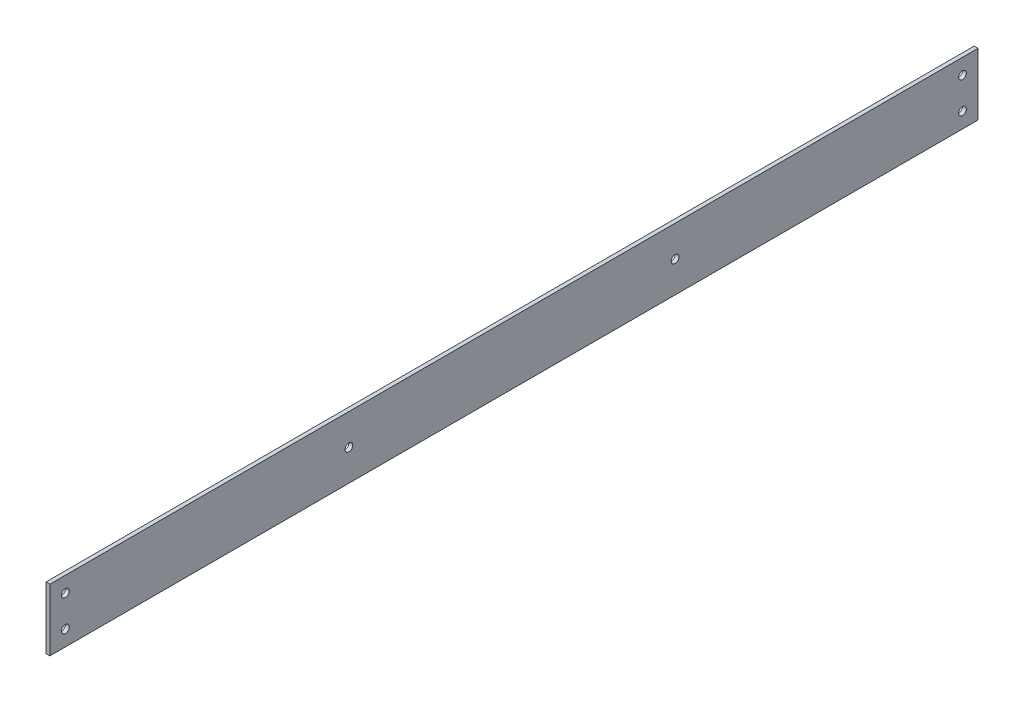
from build123d import *

# Parameters (mm, degrees)
SKETCH1_W           = 3.175
SKETCH1_H           = 50.8
BOSS_EXTRUDE1_DEPTH = 809.625
SKETCH2_R           = 3.175
CUT_EXTRUDE1_DEPTH  = 4.175
SKETCH3_W           = 25.4
SKETCH3_H           = 50.8
CUT_EXTRUDE2_DEPTH  = 4.175
SKETCH4_R           = 3.175
CUT_EXTRUDE3_DEPTH  = 4.175


with BuildPart() as part:
    # Sketch1 → Boss-Extrude1 (new body)
    with BuildSketch(Plane.XY):
        Rectangle(SKETCH1_W, SKETCH1_H)
    extrude(amount=BOSS_EXTRUDE1_DEPTH)

    # Sketch2 → Cut-Extrude1 (cut, through all)
    with BuildSketch(Plane(origin=(1.5875, 0, 0), x_dir=(0, 0, -1), z_dir=(1, 0, 0))):
        with Locations((-38.1, 12.7)):
            Circle(SKETCH2_R)
        with Locations((-38.1, -12.7)):
            Circle(SKETCH2_R)
        with Locations((-771.525, 12.7)):
            Circle(SKETCH2_R)
        with Locations((-771.525, -12.7)):
            Circle(SKETCH2_R)
    extrude(amount=-CUT_EXTRUDE1_DEPTH, mode=Mode.SUBTRACT)

    # Sketch3 → Cut-Extrude2 (cut, through all)
    with BuildSketch(Plane.ZY.offset(1.5875)):
        with Locations((796.925, 0)):
            Rectangle(SKETCH3_W, SKETCH3_H)
        with Locations((12.7, 0)):
            Rectangle(SKETCH3_W, SKETCH3_H)
    extrude(amount=-CUT_EXTRUDE2_DEPTH, mode=Mode.SUBTRACT)

    # Sketch4 → Cut-Extrude3 (cut, through all)
    with BuildSketch(Plane.ZY.offset(1.5875)):
        with Locations((273.05, 0)):
            Circle(SKETCH4_R)
        with Locations((539.75, 0)):
            Circle(SKETCH4_R)
    extrude(amount=-CUT_EXTRUDE3_DEPTH, mode=Mode.SUBTRACT)


solid = part.part
